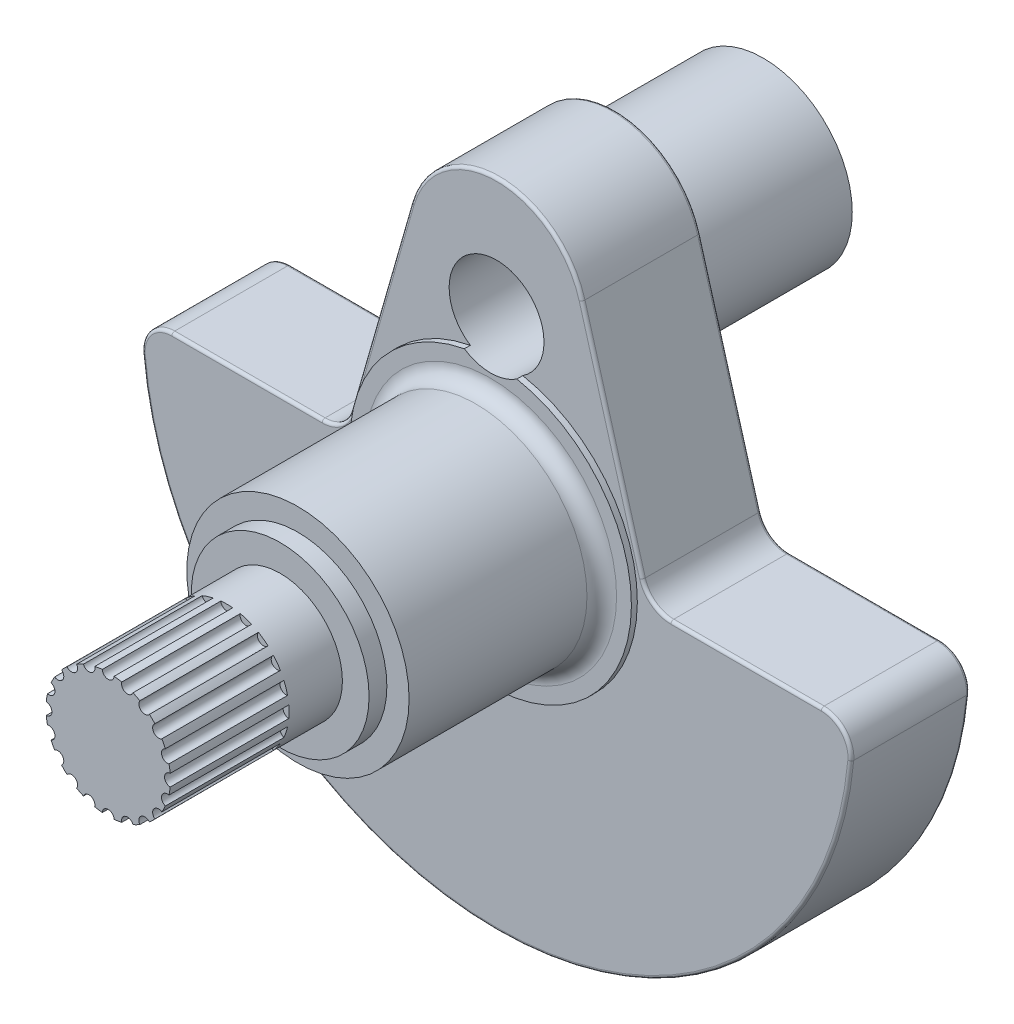
from build123d import *

# Parameters (mm, degrees)
BOSS_EXTRUDE1_DEPTH     = 20
SKETCH2_R               = 47.5
BOSS_EXTRUDE2_DEPTH     = 2
FILLET1_R               = 10
SKETCH3_R               = 37.5
BOSS_EXTRUDE3_DEPTH     = 65
SKETCH4_R               = 30
BOSS_EXTRUDE4_DEPTH     = 6
SKETCH5_R               = 21
BOSS_EXTRUDE5_DEPTH     = 58
FILLET2_R               = 5
SKETCH6_R               = 30
BOSS_EXTRUDE6_DEPTH     = 50
SKETCH7_R               = 21
CUT_EXTRUDE1_DEPTH      = 25
SKETCH8_R               = 11
CUT_EXTRUDE2_DEPTH      = 197
SKETCH9_R               = 16
CUT_EXTRUDE3_DEPTH      = 132
CUT_EXTRUDE3_DEPTH_BACK = 40
FILLET3_R               = 1
SKETCH10_R              = 2
CUT_EXTRUDE4_DEPTH      = 40
CIRPATTERN1_COUNT       = 20


with BuildPart() as part:
    # Sketch1 → Boss-Extrude1 (new body, symmetric)
    with BuildSketch(Plane.XY):
        with BuildLine():
            Line((-120, -70), (-51.281160079, -70))
            Line((-51.281160079, -70), (-28.837850878, 8.269120675))
            ThreePointArc((-28.837850878, 8.269120675), (0, 30), (28.837850878, 8.269120675))
            Line((28.837850878, 8.269120675), (51.281160079, -70))
            Line((51.281160079, -70), (120, -70))
            ThreePointArc((120, -70), (0, -190), (-120, -70))
        make_face()
    extrude(amount=BOSS_EXTRUDE1_DEPTH, both=True)

    # Sketch2 → Boss-Extrude2 (add)
    with BuildSketch(Plane.XY.offset(20)):
        with Locations((0, -70)):
            Circle(SKETCH2_R)
    extrude(amount=BOSS_EXTRUDE2_DEPTH)

    # Fillet1
    fillet1_edges = [part.edges().sort_by_distance(p)[0] for p in [
        (51.281160079, -70, 0),
        (120, -70, 0),
        (-120, -70, 0),
        (-51.281160079, -70, 0),
    ]]
    fillet(fillet1_edges, radius=FILLET1_R)

    # Sketch3 → Boss-Extrude3 (add)
    with BuildSketch(Plane.XY.offset(22)):
        with Locations((0, -70)):
            Circle(SKETCH3_R)
    extrude(amount=BOSS_EXTRUDE3_DEPTH)

    # Sketch4 → Boss-Extrude4 (add)
    with BuildSketch(Plane.XY.offset(87)):
        with Locations((0, -70)):
            Circle(SKETCH4_R)
    extrude(amount=BOSS_EXTRUDE4_DEPTH)

    # Sketch5 → Boss-Extrude5 (add)
    with BuildSketch(Plane.XY.offset(93)):
        with Locations((0, -70)):
            Circle(SKETCH5_R)
    extrude(amount=BOSS_EXTRUDE5_DEPTH)

    # Fillet2
    fillet2_edges = [part.edges().sort_by_distance(p)[0] for p in [
        (-37.5, -70, 22),
    ]]
    fillet(fillet2_edges, radius=FILLET2_R)

    # Sketch6 → Boss-Extrude6 (add)
    with BuildSketch(Plane(origin=(0, 0, -20), x_dir=(-1, 0, 0), z_dir=(0, 0, -1))):
        with Locations(Location((0, -10, 0), (0, 0, 180))):  # turned: the seam where the file's is
            Circle(SKETCH6_R)
    extrude(amount=BOSS_EXTRUDE6_DEPTH)

    # Sketch7 → Cut-Extrude1 (cut)
    with BuildSketch(Plane(origin=(0, 0, -70), x_dir=(-1, 0, 0), z_dir=(0, 0, -1))):
        with Locations((0, -10)):
            Circle(SKETCH7_R)
    extrude(amount=-CUT_EXTRUDE1_DEPTH, mode=Mode.SUBTRACT)

    # Sketch8 → Cut-Extrude2 (cut, through all)
    with BuildSketch(Plane(origin=(0, 0, -45), x_dir=(-1, 0, 0), z_dir=(0, 0, -1))):
        with Locations((0, -10)):
            Circle(SKETCH8_R)
    extrude(amount=-CUT_EXTRUDE2_DEPTH, mode=Mode.SUBTRACT)

    # Sketch9 → Cut-Extrude3 (cut, two sides)
    with BuildSketch(Plane.XY.offset(20)) as cut_extrude3_sk:
        with Locations(Location((0, -10, 0), (0, 0, 236.429196284))):  # turned: the seam where the file's is
            Circle(SKETCH9_R)
    extrude(amount=CUT_EXTRUDE3_DEPTH, mode=Mode.SUBTRACT)
    extrude(cut_extrude3_sk.sketch, amount=-CUT_EXTRUDE3_DEPTH_BACK, mode=Mode.SUBTRACT)

    # Fillet3
    fillet3_edges = [part.edges().sort_by_distance(p)[0] for p in [
        (84.180606041, -70, -20),
        (84.180606041, -70, 20),
        (39.020967249, -27.243626442, -20),
        (0, -190, -20),
        (-84.180606041, -70, -20),
        (-116.93000096, -73.258001375, -20),
        (116.93000096, -73.258001375, -20),
        (0, -190, 20),
        (-84.180606041, -70, 20),
        (39.020967249, -27.243626442, 20),
        (-116.93000096, -73.258001375, 20),
        (116.93000096, -73.258001375, 20),
        (52.798550348, -67.9863551, -20),
        (52.798550348, -67.9863551, 20),
        (-52.798550348, -67.9863551, -20),
        (-52.798550348, -67.9863551, 20),
        (0, 30, 20),
        (-39.020967249, -27.243626442, 20),
        (-39.020967249, -27.243626442, -20),
        (0, 30, -20),
    ]]
    fillet(fillet3_edges, radius=FILLET3_R)

    # Sketch10 → Cut-Extrude4 (cut)
    with BuildSketch(Plane.XY.offset(151)):
        with Locations((0, -49)):
            Circle(SKETCH10_R)
    cut_extrude4 = extrude(amount=-CUT_EXTRUDE4_DEPTH, mode=Mode.SUBTRACT)

    # CirPattern1: Cut-Extrude4 ×20 about axis
    cirpattern1_axis = Axis((0, -70, 0), (0, 0, 1))
    for i in range(1, CIRPATTERN1_COUNT):
        add(cut_extrude4.rotate(cirpattern1_axis, i * 360 / CIRPATTERN1_COUNT), mode=Mode.SUBTRACT)


solid = part.part
